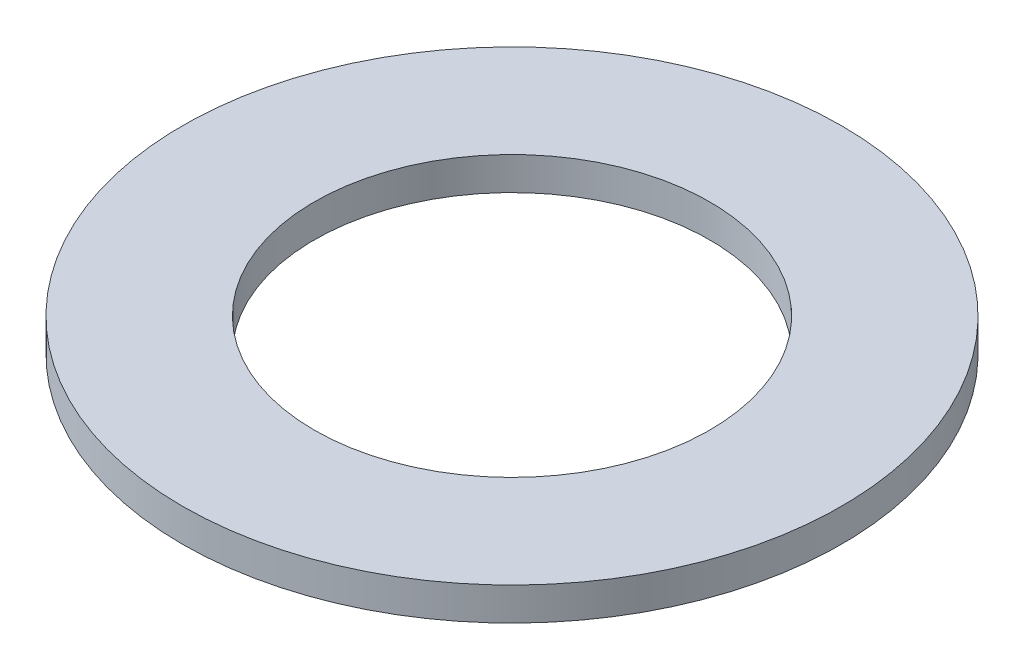
from build123d import *

# Parameters (mm, degrees)
SKETCH1_R           = 5
SKETCH1_R_2         = 3
BOSS_EXTRUDE2_DEPTH = 0.5
CUT_EXTRUDE5_DEPTH  = 0.2


with BuildPart() as part:
    # Sketch1 → Boss-Extrude2 (new body)
    with BuildSketch(Plane(origin=(0, 0, 0), x_dir=(1, 0, 0), z_dir=(0, 1, 0))):
        Circle(SKETCH1_R)
        Circle(SKETCH1_R_2, mode=Mode.SUBTRACT)
    extrude(amount=BOSS_EXTRUDE2_DEPTH)

    # Sketch4 → Cut-Extrude5 (cut)
    with BuildSketch(Plane(origin=(0, 0, 0), x_dir=(1, 0, 0), z_dir=(0, 1, 0))):
        with BuildLine():
            Line((-1.227705378, 2.901045691), (-4.555523725, 1.283756278))
            ThreePointArc((-4.555523725, 1.283756278), (-4.689175287, 1.32998679), (-4.642944775, 1.463638351))
            Line((-4.642944775, 1.463638351), (-1.315126427, 3.080927764))
            ThreePointArc((-1.315126427, 3.080927764), (-1.181474866, 3.034697252), (-1.227705378, 2.901045691))
        make_face()
        with BuildLine():
            Line((0.388990404, 3.128300785), (-3.301629531, 3.391596243))
            ThreePointArc((-3.301629531, 3.391596243), (-3.394259922, 3.498458821), (-3.287397344, 3.591089212))
            Line((-3.287397344, 3.591089212), (0.403222591, 3.327793755))
            ThreePointArc((0.403222591, 3.327793755), (0.495852982, 3.220931177), (0.388990404, 3.128300785))
        make_face()
        with BuildLine():
            Line((1.902717568, 2.516761579), (-1.161805322, 4.590092101))
            ThreePointArc((-1.161805322, 4.590092101), (-1.188594305, 4.728953005), (-1.049733402, 4.755741987))
            Line((-1.049733402, 4.755741987), (2.014789488, 2.682411465))
            ThreePointArc((2.014789488, 2.682411465), (2.041578471, 2.543550562), (1.902717568, 2.516761579))
        make_face()
        with BuildLine():
            Line((2.907874144, 1.230289509), (1.290584731, 4.558107857))
            ThreePointArc((1.290584731, 4.558107857), (1.336815243, 4.691759418), (1.470466804, 4.645528907))
            Line((1.470466804, 4.645528907), (3.087756217, 1.317710559))
            ThreePointArc((3.087756217, 1.317710559), (3.041525705, 1.184058998), (2.907874144, 1.230289509))
        make_face()
        with BuildLine():
            Line((3.135129238, -0.386406272), (3.398424696, 3.304213663))
            ThreePointArc((3.398424696, 3.304213663), (3.505287274, 3.396844054), (3.597917665, 3.289981476))
            Line((3.597917665, 3.289981476), (3.334622208, -0.400638459))
            ThreePointArc((3.334622208, -0.400638459), (3.22775963, -0.49326885), (3.135129238, -0.386406272))
        make_face()
        with BuildLine():
            Line((2.523590032, -1.900133436), (4.596920554, 1.164389454))
            ThreePointArc((4.596920554, 1.164389454), (4.735781458, 1.191178437), (4.76257044, 1.052317534))
            Line((4.76257044, 1.052317534), (2.689239918, -2.012205357))
            ThreePointArc((2.689239918, -2.012205357), (2.550379015, -2.038994339), (2.523590032, -1.900133436))
        make_face()
        with BuildLine():
            Line((1.237117962, -2.905290012), (4.56493631, -1.2880006))
            ThreePointArc((4.56493631, -1.2880006), (4.698587871, -1.334231111), (4.65235736, -1.467882672))
            Line((4.65235736, -1.467882672), (1.324539012, -3.085172085))
            ThreePointArc((1.324539012, -3.085172085), (1.190887451, -3.038941573), (1.237117962, -2.905290012))
        make_face()
        with BuildLine():
            Line((-0.379577819, -3.132545106), (3.311042116, -3.395840564))
            ThreePointArc((3.311042116, -3.395840564), (3.403672507, -3.502703142), (3.296809929, -3.595333533))
            Line((3.296809929, -3.595333533), (-0.393810006, -3.332038076))
            ThreePointArc((-0.393810006, -3.332038076), (-0.486440397, -3.225175498), (-0.379577819, -3.132545106))
        make_face()
        with BuildLine():
            Line((-1.893304983, -2.521005901), (1.171217907, -4.594336423))
            ThreePointArc((1.171217907, -4.594336423), (1.19800689, -4.733197326), (1.059145987, -4.759986309))
            Line((1.059145987, -4.759986309), (-2.005376904, -2.686655787))
            ThreePointArc((-2.005376904, -2.686655787), (-2.032165886, -2.547794883), (-1.893304983, -2.521005901))
        make_face()
        with BuildLine():
            Line((-2.898461559, -1.234533831), (-1.281172147, -4.562352178))
            ThreePointArc((-1.281172147, -4.562352178), (-1.327402658, -4.69600374), (-1.461054219, -4.649773228))
            Line((-1.461054219, -4.649773228), (-3.078343632, -1.32195488))
            ThreePointArc((-3.078343632, -1.32195488), (-3.03211312, -1.188303319), (-2.898461559, -1.234533831))
        make_face()
        with BuildLine():
            Line((-3.125716653, 0.382161951), (-3.389012111, -3.308457984))
            ThreePointArc((-3.389012111, -3.308457984), (-3.495874689, -3.401088375), (-3.58850508, -3.294225797))
            Line((-3.58850508, -3.294225797), (-3.325209623, 0.396394138))
            ThreePointArc((-3.325209623, 0.396394138), (-3.218347045, 0.489024529), (-3.125716653, 0.382161951))
        make_face()
        with BuildLine():
            Line((-2.514177448, 1.895889115), (-4.58750797, -1.168633775))
            ThreePointArc((-4.58750797, -1.168633775), (-4.726368873, -1.195422758), (-4.753157856, -1.056561855))
            Line((-4.753157856, -1.056561855), (-2.679827334, 2.007961035))
            ThreePointArc((-2.679827334, 2.007961035), (-2.54096643, 2.034750018), (-2.514177448, 1.895889115))
        make_face()
    extrude(amount=CUT_EXTRUDE5_DEPTH, mode=Mode.SUBTRACT)


solid = part.part
